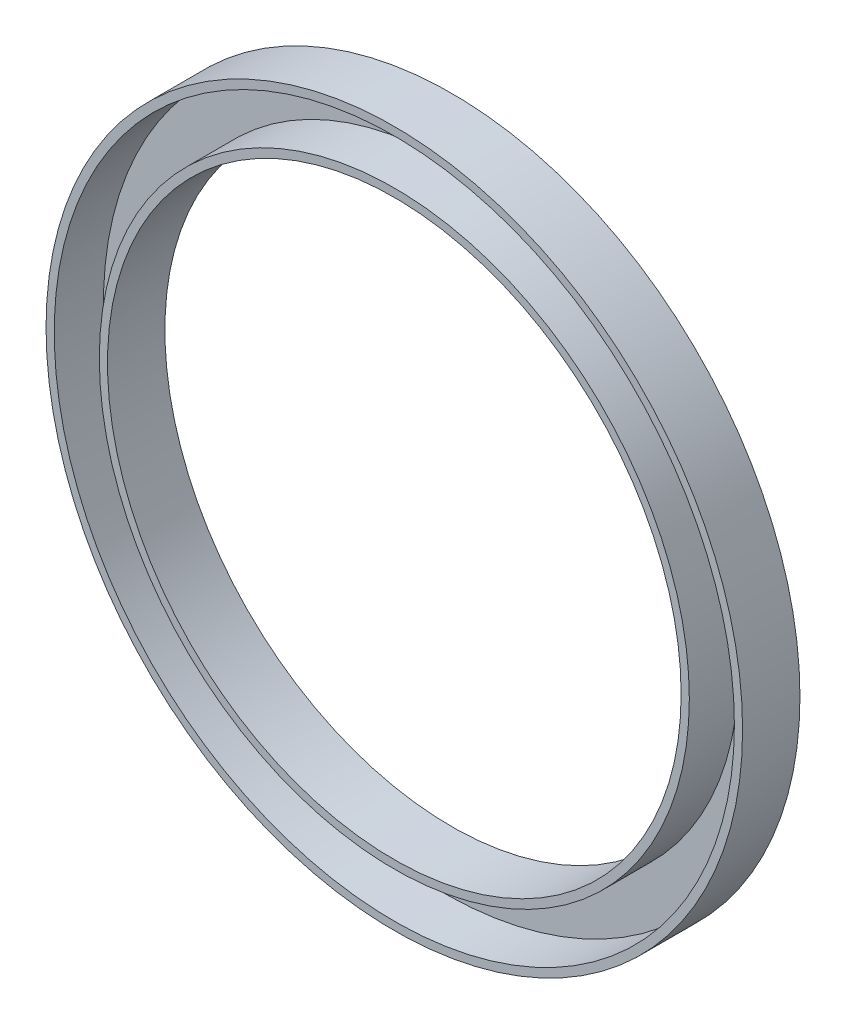
from build123d import *

# Parameters (mm, degrees)
SKETCH_1_R      = 85
SKETCH_1_R_2    = 70
EXTRUDE_1_DEPTH = 14
SHELL_1_T       = -2


with BuildPart() as part:
    # 草图1 → 凸台-拉伸1 (new body)
    with BuildSketch(Plane.XY):
        Circle(SKETCH_1_R)
        Circle(SKETCH_1_R_2, mode=Mode.SUBTRACT)
    extrude(amount=EXTRUDE_1_DEPTH)

    # 抽壳1
    shell_1_openings = [part.faces().sort_by_distance(p)[0] for p in [
        (-82.595836944, 0, 14),
    ]]
    offset(amount=SHELL_1_T, openings=shell_1_openings, kind=Kind.INTERSECTION)


solid = part.part
